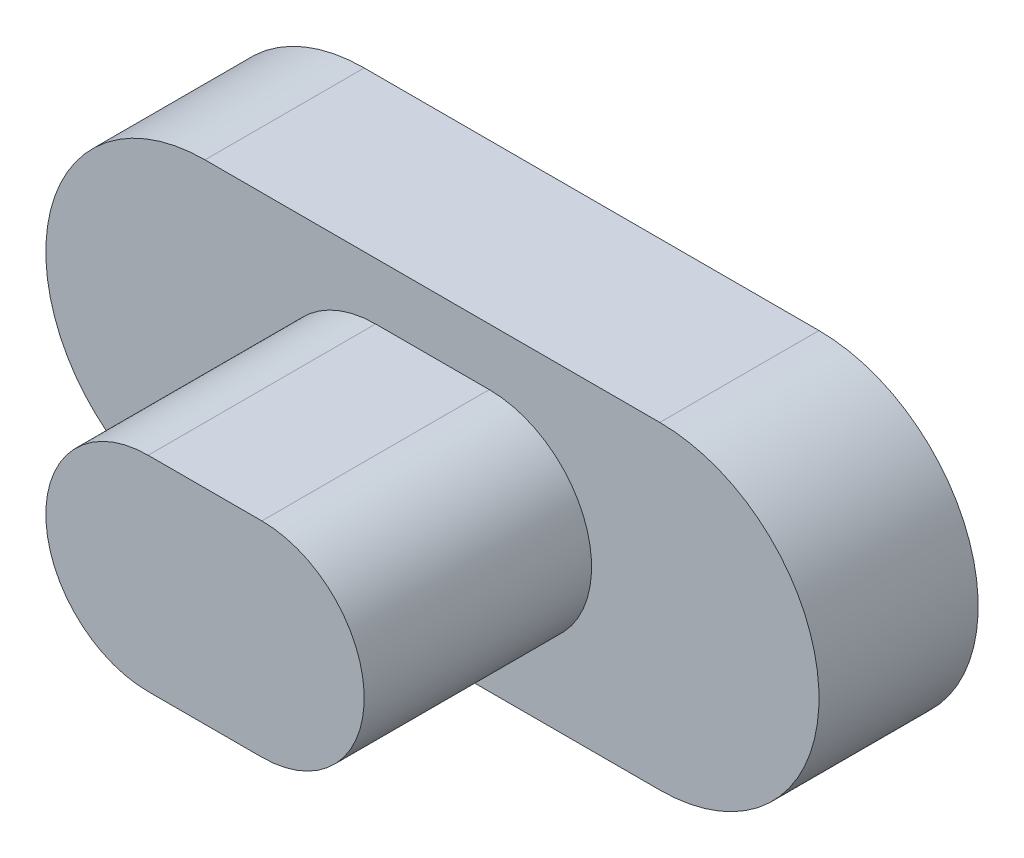
from build123d import *

# Parameters (mm, degrees)
EXTRUDE_1_DEPTH     = 1.4
EXTRUDE_2_DEPTH     = 2
SKETCH_4_W          = 1.6
SKETCH_4_H          = 1.2
CUT_EXTRUDE_1_DEPTH = 2


with BuildPart() as part:
    # 草图2 → 凸台-拉伸1 (new body)
    with BuildSketch(Plane.XY):
        with BuildLine():
            Line((-2, 1.4), (2, 1.4))
            ThreePointArc((2, 1.4), (3.4, 0), (2, -1.4))
            Line((2, -1.4), (-2, -1.4))
            ThreePointArc((-2, -1.4), (-3.4, 0), (-2, 1.4))
        make_face()
    extrude(amount=EXTRUDE_1_DEPTH)

    # 草图3 → 凸台-拉伸2 (add)
    with BuildSketch(Plane.XY.offset(1.4)):
        with BuildLine():
            Line((-0.5, 0.9), (0.5, 0.9))
            ThreePointArc((0.5, 0.9), (1.4, 0), (0.5, -0.9))
            Line((0.5, -0.9), (-0.5, -0.9))
            ThreePointArc((-0.5, -0.9), (-1.4, 0), (-0.5, 0.9))
        make_face()
    extrude(amount=EXTRUDE_2_DEPTH)

    # 草图4 → 切除-拉伸1 (cut)
    with BuildSketch(Plane(origin=(0, 0, 0), x_dir=(-1, 0, 0), z_dir=(0, 0, -1))):
        Rectangle(SKETCH_4_W, SKETCH_4_H)
    extrude(amount=-CUT_EXTRUDE_1_DEPTH, mode=Mode.SUBTRACT)


solid = part.part
